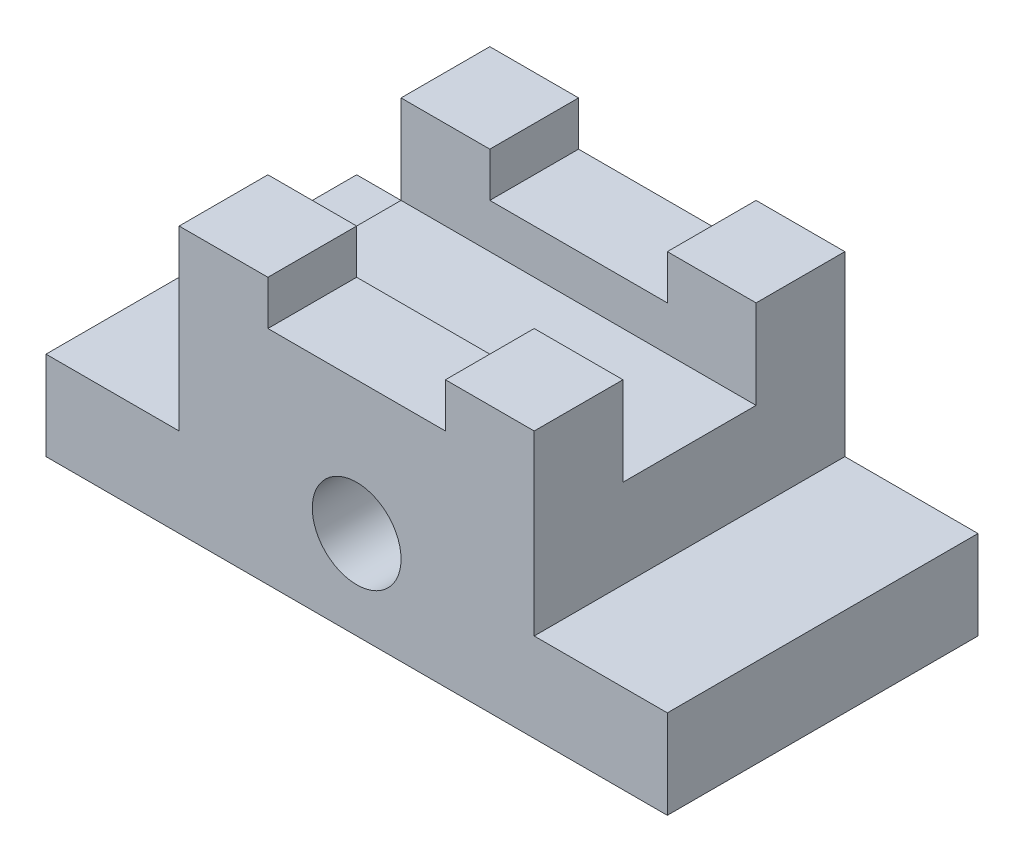
from build123d import *

# Parameters (mm, degrees)
SKETCH1_W           = 70
SKETCH1_H           = 35
BOSS_EXTRUDE1_DEPTH = 30
SKETCH2_W           = 15
SKETCH2_H           = 35
CUT_EXTRUDE1_DEPTH  = 20
SKETCH3_W           = 15
SKETCH3_H           = 35
CUT_EXTRUDE2_DEPTH  = 20
SKETCH4_W           = 15
SKETCH4_H           = 10
CUT_EXTRUDE3_DEPTH  = 41
SKETCH6_W           = 20
SKETCH6_H           = 5
CUT_EXTRUDE4_DEPTH  = 41
SKETCH7_R           = 5
CUT_EXTRUDE5_DEPTH  = 36


with BuildPart() as part:
    # Sketch1 → Boss-Extrude1 (new body)
    with BuildSketch(Plane(origin=(0, 0, 0), x_dir=(1, 0, 0), z_dir=(0, 1, 0))):
        with Locations((35, 17.5)):
            Rectangle(SKETCH1_W, SKETCH1_H)
    extrude(amount=BOSS_EXTRUDE1_DEPTH)

    # Sketch2 → Cut-Extrude1 (cut)
    with BuildSketch(Plane(origin=(0, 30, 0), x_dir=(1, 0, 0), z_dir=(0, 1, 0))):
        with Locations((7.5, 17.5)):
            Rectangle(SKETCH2_W, SKETCH2_H)
    extrude(amount=-CUT_EXTRUDE1_DEPTH, mode=Mode.SUBTRACT)

    # Sketch3 → Cut-Extrude2 (cut)
    with BuildSketch(Plane(origin=(0, 30, 0), x_dir=(1, 0, 0), z_dir=(0, 1, 0))):
        with Locations((62.5, 17.5)):
            Rectangle(SKETCH3_W, SKETCH3_H)
    extrude(amount=-CUT_EXTRUDE2_DEPTH, mode=Mode.SUBTRACT)

    # Sketch4 → Cut-Extrude3 (cut)
    with BuildSketch(Plane(origin=(55, 0, 0), x_dir=(0, 0, -1), z_dir=(1, 0, 0))):
        with Locations((17.5, 25)):
            Rectangle(SKETCH4_W, SKETCH4_H)
    extrude(amount=-CUT_EXTRUDE3_DEPTH, mode=Mode.SUBTRACT)

    # Sketch6 → Cut-Extrude4 (cut)
    with BuildSketch(Plane.XY):
        with Locations((35, 27.5)):
            Rectangle(SKETCH6_W, SKETCH6_H)
    extrude(amount=-CUT_EXTRUDE4_DEPTH, mode=Mode.SUBTRACT)

    # Sketch7 → Cut-Extrude5 (cut, through all)
    with BuildSketch(Plane.XY):
        with Locations((35, 10)):
            Circle(SKETCH7_R)
    extrude(amount=-CUT_EXTRUDE5_DEPTH, mode=Mode.SUBTRACT)


solid = part.part
